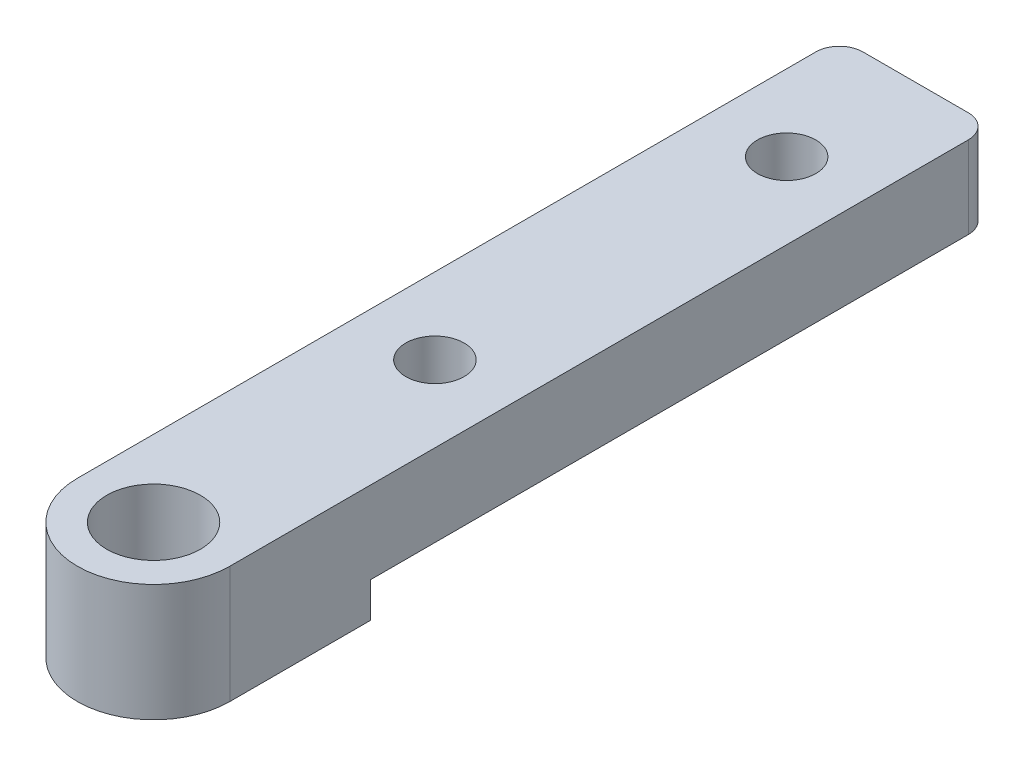
from build123d import *

# Parameters (mm, degrees)
SKETCH1_R                  = 3.99415
BOSS_EXTRUDE1_DEPTH        = 10
SKETCH2_W                  = 13
SKETCH2_H                  = 53
CUT_EXTRUDE1_DEPTH         = 3
F_10_CLEARANCE_HOLE1_D     = 4.9784
F_10_CLEARANCE_HOLE1_DEPTH = 40
F_10_CLEARANCE_HOLE1_TIP   = 1.495662253
FILLET1_R                  = 2


with BuildPart() as part:
    # Sketch1 → Boss-Extrude1 (new body)
    with BuildSketch(Plane(origin=(0, 0, 0), x_dir=(1, 0, 0), z_dir=(0, 1, 0))):
        with BuildLine():
            Line((-6.5, 0), (-6.5, 65))
            Line((-6.5, 65), (6.5, 65))
            Line((6.5, 65), (6.5, 0))
            ThreePointArc((6.5, 0), (0, -6.5), (-6.5, 0))
        make_face()
        with Locations(Location((0, 0, 0), (0, 0, 270))):  # turned: the seam where the file's is
            Circle(SKETCH1_R, mode=Mode.SUBTRACT)
    extrude(amount=BOSS_EXTRUDE1_DEPTH)

    # Sketch2 → Cut-Extrude1 (cut)
    with BuildSketch(Plane.XZ):
        with Locations((0, -38.5)):
            Rectangle(SKETCH2_W, SKETCH2_H)
    extrude(amount=-CUT_EXTRUDE1_DEPTH, mode=Mode.SUBTRACT)

    # #10 Clearance Hole1
    with Locations(Plane.XZ.offset(-3)):
        with Locations((0, -54), (0, -24)):
            Hole(F_10_CLEARANCE_HOLE1_D / 2, depth=F_10_CLEARANCE_HOLE1_DEPTH)
            with Locations((0, 0, -(F_10_CLEARANCE_HOLE1_DEPTH + F_10_CLEARANCE_HOLE1_TIP / 2))):  # 118° drill point
                Cone(0, F_10_CLEARANCE_HOLE1_D / 2, F_10_CLEARANCE_HOLE1_TIP, mode=Mode.SUBTRACT)

    # Fillet1
    fillet1_edges = [part.edges().sort_by_distance(p)[0] for p in [
        (-6.5, 6.5, -65),
        (6.5, 6.5, -65),
    ]]
    fillet(fillet1_edges, radius=FILLET1_R)


solid = part.part
